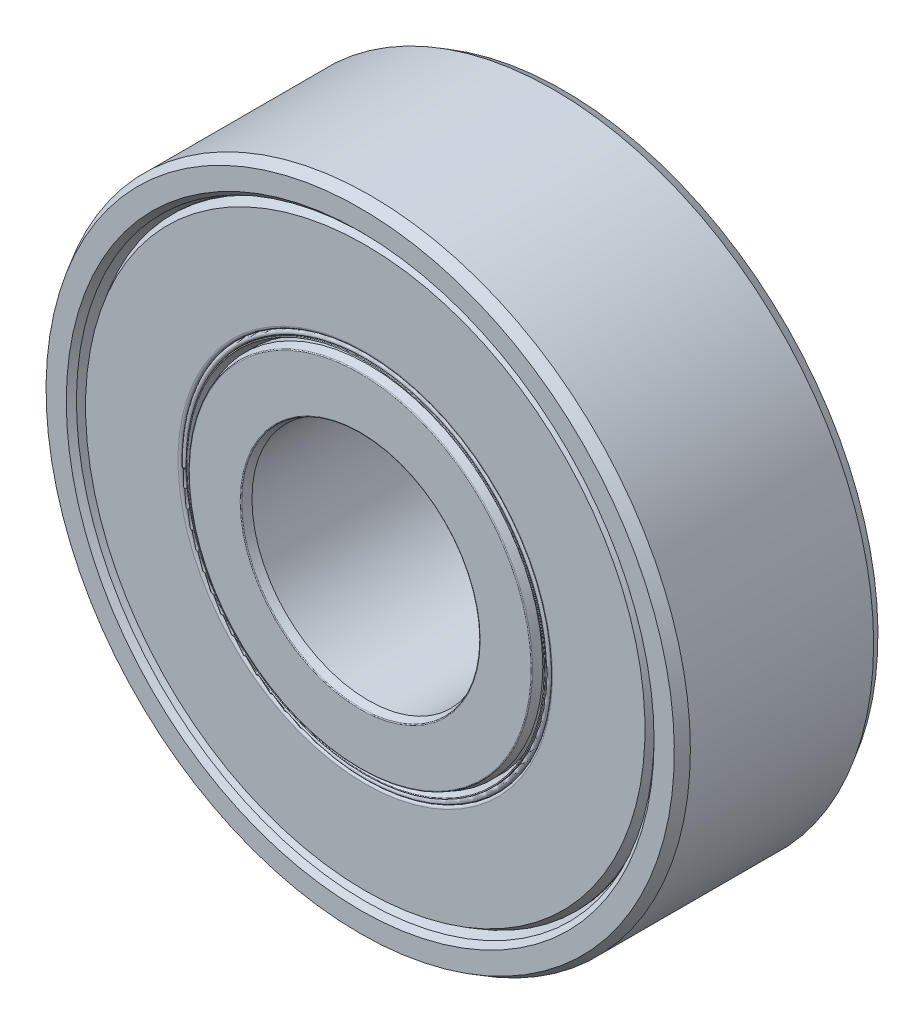
from build123d import *

# Parameters (mm, degrees)
CIRPATTERN1_COUNT = 7


with BuildPart() as part:
    # Sketch3 → Revolve1 (revolve)
    with BuildSketch(Plane(origin=(0, 0, 0), x_dir=(0, 0, -1), z_dir=(1, 0, 0))):
        with BuildLine():
            Line((-2.945227749, 9.79), (-3.325, 9.928225795))
            Line((-3.325, 9.928225795), (-3.5, 10.103225795))
            Line((-3.5, 10.103225795), (-3.5, 10.797927406))
            Line((-3.5, 10.797927406), (-3.15, 11))
            Line((-3.15, 11), (3.15, 11))
            Line((3.15, 11), (3.5, 10.797927406))
            Line((3.5, 10.797927406), (3.5, 10.103225795))
            Line((3.5, 10.103225795), (3.325, 9.928225795))
            Line((3.325, 9.928225795), (2.945227749, 9.79))
            Line((2.945227749, 9.79), (1.631, 9.79))
            ThreePointArc((1.631, 9.79), (0, 10.395), (-1.631, 9.79))
            Line((-1.631, 9.79), (-2.945227749, 9.79))
        make_face()
    revolve(axis=Axis((0, 0, 3.5), (0, 0, -1)))


with BuildPart() as body_2:
    # Sketch4 → Revolve2 (revolve)
    with BuildSketch(Plane(origin=(0, 0, 0), x_dir=(0, 0, -1), z_dir=(1, 0, 0))):
        with BuildLine():
            Line((-3.22, 4), (-3.476970705, 4.093529688))
            ThreePointArc((-3.476970705, 4.093529688), (-3.493670322, 4.106343754), (-3.5, 4.126418929))
            Line((-3.5, 4.126418929), (-3.5, 5.87162074))
            ThreePointArc((-3.5, 5.87162074), (-3.493670322, 5.891695915), (-3.476970705, 5.904509982))
            Line((-3.476970705, 5.904509982), (-3.22, 5.998039669))
            Line((-3.22, 5.998039669), (-1.631, 5.998039669))
            ThreePointArc((-1.631, 5.998039669), (0, 5.393039669), (1.631, 5.998039669))
            Line((1.631, 5.998039669), (3.22, 5.998039669))
            Line((3.22, 5.998039669), (3.476970705, 5.904509982))
            ThreePointArc((3.476970705, 5.904509982), (3.493670322, 5.891695915), (3.5, 5.87162074))
            Line((3.5, 5.87162074), (3.5, 4.126418929))
            ThreePointArc((3.5, 4.126418929), (3.493670322, 4.106343754), (3.476970705, 4.093529688))
            Line((3.476970705, 4.093529688), (3.22, 4))
            Line((3.22, 4), (-3.22, 4))
        make_face()
    revolve(axis=Axis((0, 0, 3.5), (0, 0, -1)))


with BuildPart() as body_3:
    # Sketch5 → Revolve3 (revolve)
    with BuildSketch(Plane(origin=(0, 0, 0), x_dir=(0, 0, -1), z_dir=(1, 0, 0))):
        with BuildLine():
            Line((-2.500980165, 7.894019835), (2.500980165, 7.894019835))
            ThreePointArc((2.500980165, 7.894019835), (0, 10.395), (-2.500980165, 7.894019835))
        make_face()
    revolve(axis=Axis((0, 7.894019835, 2.500980165), (0, 0, -1)))


with BuildPart() as cirpattern1_1:
    # CirPattern1: pattern copy
    add(body_3.part.rotate(Axis((0, 0, 0), (0, 0, 1)), 1 * 360 / CIRPATTERN1_COUNT))


with BuildPart() as cirpattern1_2:
    # CirPattern1: pattern copy
    add(body_3.part.rotate(Axis((0, 0, 0), (0, 0, 1)), 2 * 360 / CIRPATTERN1_COUNT))


with BuildPart() as cirpattern1_3:
    # CirPattern1: pattern copy
    add(body_3.part.rotate(Axis((0, 0, 0), (0, 0, 1)), 3 * 360 / CIRPATTERN1_COUNT))


with BuildPart() as cirpattern1_4:
    # CirPattern1: pattern copy
    add(body_3.part.rotate(Axis((0, 0, 0), (0, 0, 1)), 4 * 360 / CIRPATTERN1_COUNT))


with BuildPart() as cirpattern1_5:
    # CirPattern1: pattern copy
    add(body_3.part.rotate(Axis((0, 0, 0), (0, 0, 1)), 5 * 360 / CIRPATTERN1_COUNT))


with BuildPart() as cirpattern1_6:
    # CirPattern1: pattern copy
    add(body_3.part.rotate(Axis((0, 0, 0), (0, 0, 1)), 6 * 360 / CIRPATTERN1_COUNT))


with BuildPart() as body_10:
    # Sketch6 → Revolve4 (revolve)
    with BuildSketch(Plane(origin=(0, 0, 0), x_dir=(0, 0, -1), z_dir=(1, 0, 0))):
        with BuildLine():
            Line((-3.021891109, 9.79), (-2.500980165, 9.79))
            Line((-2.500980165, 9.79), (-2.500980165, 6.348039669))
            Line((-2.500980165, 6.348039669), (-3.2375, 6.348039669))
            ThreePointArc((-3.2375, 6.348039669), (-3.299371843, 6.373667826), (-3.325, 6.435539669))
            Line((-3.325, 6.435539669), (-3.325, 9.615))
            Line((-3.325, 9.615), (-3.021891109, 9.79))
        make_face()
        with BuildLine():
            Line((3.2375, 6.348039669), (2.500980165, 6.348039669))
            Line((2.500980165, 6.348039669), (2.500980165, 9.79))
            Line((2.500980165, 9.79), (3.021891109, 9.79))
            Line((3.021891109, 9.79), (3.325, 9.615))
            Line((3.325, 9.615), (3.325, 6.435539669))
            ThreePointArc((3.325, 6.435539669), (3.299371843, 6.373667826), (3.2375, 6.348039669))
        make_face()
    revolve(axis=Axis((0, 0, 3.5), (0, 0, -1)))


with BuildPart() as body_11:
    # Sketch7 → Revolve5 (revolve)
    with BuildSketch(Plane(origin=(0, 0, 0), x_dir=(0, 0, -1), z_dir=(1, 0, 0))):
        with BuildLine():
            Line((-2.500980165, 5.998039669), (-2.925938883, 5.998039669))
            Line((-2.925938883, 5.998039669), (-3.313485353, 6.139095049))
            ThreePointArc((-3.313485353, 6.139095049), (-3.324734136, 6.158578513), (-3.3075, 6.173039669))
            Line((-3.3075, 6.173039669), (-3.2375, 6.173039669))
            ThreePointArc((-3.2375, 6.173039669), (-3.325, 6.260539669), (-3.2375, 6.348039669))
            Line((-3.2375, 6.348039669), (-2.500980165, 6.348039669))
            Line((-2.500980165, 6.348039669), (-2.500980165, 5.998039669))
        make_face()
        with BuildLine():
            Line((2.500980165, 6.348039669), (2.500980165, 5.998039669))
            Line((2.500980165, 5.998039669), (2.925938883, 5.998039669))
            Line((2.925938883, 5.998039669), (3.313485353, 6.139095049))
            ThreePointArc((3.313485353, 6.139095049), (3.324734136, 6.158578513), (3.3075, 6.173039669))
            Line((3.3075, 6.173039669), (3.2375, 6.173039669))
            ThreePointArc((3.2375, 6.173039669), (3.325, 6.260539669), (3.2375, 6.348039669))
            Line((3.2375, 6.348039669), (2.500980165, 6.348039669))
        make_face()
    revolve(axis=Axis((0, 0, 3.5), (0, 0, -1)))


solid = Compound([part.part, body_2.part, body_3.part, cirpattern1_1.part, cirpattern1_2.part, cirpattern1_3.part, cirpattern1_4.part, cirpattern1_5.part, cirpattern1_6.part, body_10.part, body_11.part])
